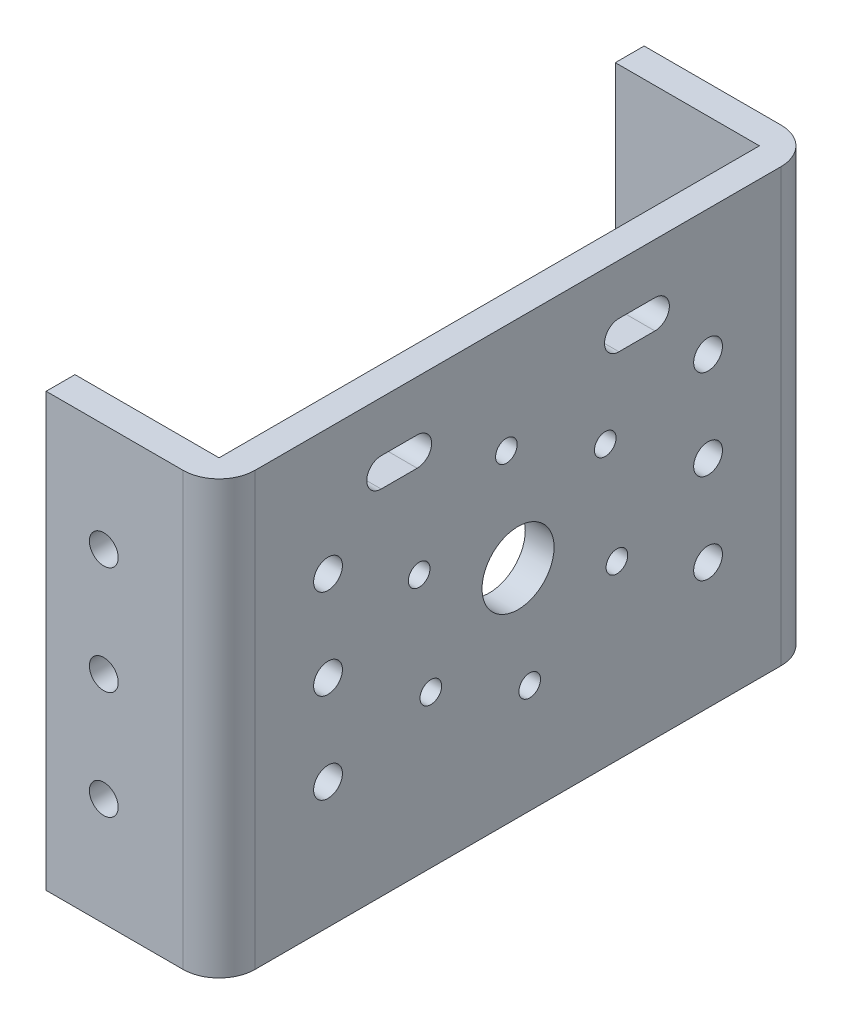
from build123d import *

# Parameters (mm, degrees)
SKETCH1_W           = 83
SKETCH1_H           = 60
BOSS_EXTRUDE1_DEPTH = 4
SKETCH2_R           = 5
CUT_EXTRUDE1_DEPTH  = 5
SKETCH4_R           = 1.5
CUT_EXTRUDE2_DEPTH  = 10
SKETCH6_R           = 2
CUT_EXTRUDE3_DEPTH  = 10
CUT_EXTRUDE4_DEPTH  = 10
SKETCH8_W           = 4.00000008
SKETCH8_H           = 60
SKETCH8_W_2         = 4
BOSS_EXTRUDE2_DEPTH = 20
FILLET1_R           = 5
SKETCH10_R          = 2
CUT_EXTRUDE5_DEPTH  = 84


with BuildPart() as part:
    # Sketch1 → Boss-Extrude1 (new body)
    with BuildSketch(Plane(origin=(0, 0, 0), x_dir=(0, 0, -1), z_dir=(1, 0, 0))):
        Rectangle(SKETCH1_W, SKETCH1_H)
    extrude(amount=BOSS_EXTRUDE1_DEPTH)

    # Sketch2 → Cut-Extrude1 (cut, through all)
    with BuildSketch(Plane(origin=(4, 0, 0), x_dir=(0, 0, -1), z_dir=(1, 0, 0))):
        Circle(SKETCH2_R)
    extrude(amount=-CUT_EXTRUDE1_DEPTH, mode=Mode.SUBTRACT)

    # Sketch4 → Cut-Extrude2 (cut)
    with BuildSketch(Plane(origin=(4, 0, 0), x_dir=(0, 0, -1), z_dir=(1, 0, 0))):
        with Locations((-13.72367631, 6.054808712)):
            Circle(SKETCH4_R)
        with Locations((-12.105456315, -8.857647962)):
            Circle(SKETCH4_R)
        with Locations((1.618219995, -14.912456674)):
            Circle(SKETCH4_R)
        with Locations((13.72367631, -6.054808712)):
            Circle(SKETCH4_R)
        with Locations((12.105456315, 8.857647962)):
            Circle(SKETCH4_R)
        with Locations((-1.618219995, 14.912456674)):
            Circle(SKETCH4_R)
    extrude(amount=-CUT_EXTRUDE2_DEPTH, mode=Mode.SUBTRACT)

    # Sketch6 → Cut-Extrude3 (cut)
    with BuildSketch(Plane(origin=(4, 0, 0), x_dir=(0, 0, -1), z_dir=(1, 0, 0))):
        with Locations((-26.375, 12.5)):
            Circle(SKETCH6_R)
        with Locations((-26.375, 0)):
            Circle(SKETCH6_R)
        with Locations((-26.375, -12.5)):
            Circle(SKETCH6_R)
        with Locations((26.375, 12.5)):
            Circle(SKETCH6_R)
        with Locations((26.375, 0)):
            Circle(SKETCH6_R)
        with Locations((26.375, -12.5)):
            Circle(SKETCH6_R)
    extrude(amount=-CUT_EXTRUDE3_DEPTH, mode=Mode.SUBTRACT)

    # Sketch7 → Cut-Extrude4 (cut)
    with BuildSketch(Plane(origin=(4, 0, 0), x_dir=(0, 0, -1), z_dir=(1, 0, 0))):
        with BuildLine():
            Line((-19, 23), (-14, 23))
            ThreePointArc((-14, 23), (-12, 21), (-14, 19))
            Line((-14, 19), (-19, 19))
            ThreePointArc((-19, 19), (-21, 21), (-19, 23))
        make_face()
        with BuildLine():
            Line((19, 23), (14, 23))
            ThreePointArc((14, 23), (12, 21), (14, 19))
            Line((14, 19), (19, 19))
            ThreePointArc((19, 19), (21, 21), (19, 23))
        make_face()
    extrude(amount=-CUT_EXTRUDE4_DEPTH, mode=Mode.SUBTRACT)

    # Sketch8 → Boss-Extrude2 (add)
    with BuildSketch(Plane.ZY):
        with Locations((-39.49999996, 0)):
            Rectangle(SKETCH8_W, SKETCH8_H)
        with Locations((39.5, 0)):
            Rectangle(SKETCH8_W_2, SKETCH8_H)
    extrude(amount=BOSS_EXTRUDE2_DEPTH)

    # Fillet1
    fillet1_edges = [part.edges().sort_by_distance(p)[0] for p in [
        (4, 0, -41.5),
        (4, 0, 41.5),
    ]]
    fillet(fillet1_edges, radius=FILLET1_R)

    # Sketch10 → Cut-Extrude5 (cut, through all)
    with BuildSketch(Plane.XY.offset(41.5)):
        with Locations((-12, 15)):
            Circle(SKETCH10_R)
        with Locations((-12, 0)):
            Circle(SKETCH10_R)
        with Locations((-12, -15)):
            Circle(SKETCH10_R)
    extrude(amount=-CUT_EXTRUDE5_DEPTH, mode=Mode.SUBTRACT)


solid = part.part
